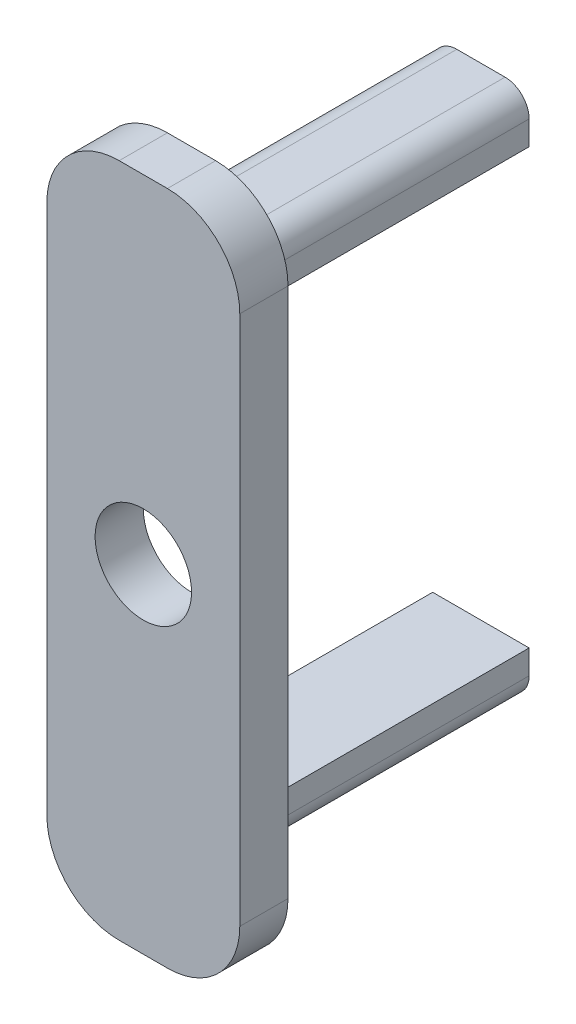
from build123d import *

# Parameters (mm, degrees)
SKETCH1_W           = 8
SKETCH1_H           = 28
BOSS_EXTRUDE1_DEPTH = 2
FILLET1_R           = 3
SKETCH2_W           = 4
SKETCH2_H           = 2
BOSS_EXTRUDE2_DEPTH = 12
FILLET2_R           = 1
SKETCH3_R           = 2
CUT_EXTRUDE3_DEPTH  = 10


with BuildPart() as part:
    # Sketch1 → Boss-Extrude1 (new body)
    with BuildSketch(Plane.XY):
        Rectangle(SKETCH1_W, SKETCH1_H)
    extrude(amount=BOSS_EXTRUDE1_DEPTH)

    # Fillet1
    fillet1_edges = [part.edges().sort_by_distance(p)[0] for p in [
        (-4, 14, 1),
        (4, 14, 1),
        (4, -14, 1),
        (-4, -14, 1),
    ]]
    fillet(fillet1_edges, radius=FILLET1_R)

    # Sketch2 → Boss-Extrude2 (add)
    with BuildSketch(Plane(origin=(0, 0, 0), x_dir=(-1, 0, 0), z_dir=(0, 0, -1))):
        with Locations((0, 10)):
            Rectangle(SKETCH2_W, SKETCH2_H)
        with Locations((0, -10)):
            Rectangle(SKETCH2_W, SKETCH2_H)
    extrude(amount=BOSS_EXTRUDE2_DEPTH)

    # Fillet2
    fillet2_edges = [part.edges().sort_by_distance(p)[0] for p in [
        (2, 11, -6),
        (-2, 11, -6),
        (-2, -11, -6),
        (2, -11, -6),
    ]]
    fillet(fillet2_edges, radius=FILLET2_R)

    # Sketch3 → Cut-Extrude3 (cut)
    with BuildSketch(Plane(origin=(0, 0, 0), x_dir=(-1, 0, 0), z_dir=(0, 0, -1))):
        Circle(SKETCH3_R)
    extrude(amount=-CUT_EXTRUDE3_DEPTH, mode=Mode.SUBTRACT)


solid = part.part
